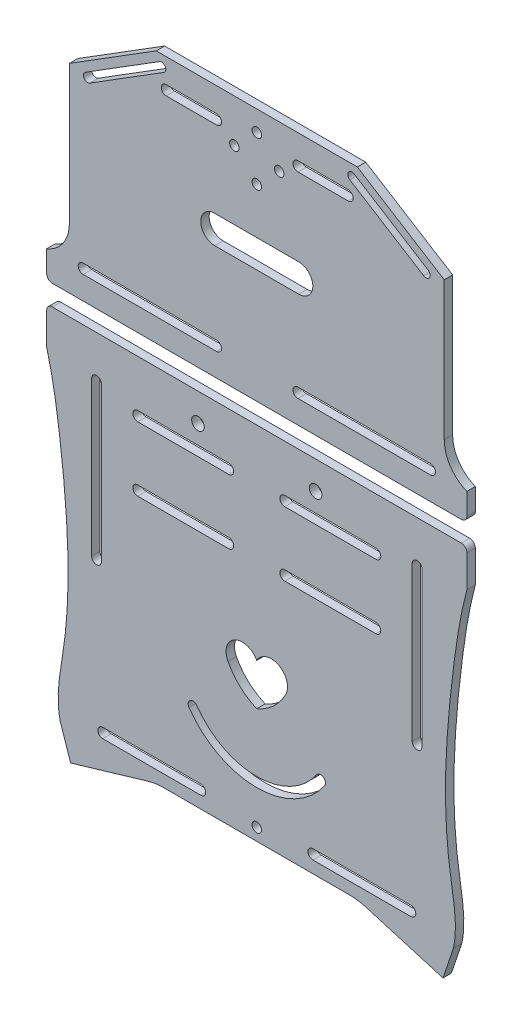
from build123d import *

# Parameters (mm, degrees)
EXTRUDE_1_DEPTH      = 3
SKETCH_7_R           = 1.75
SKETCH_7_R_2         = 2.25
CUT_EXTRUDE_2_DEPTH  = 143.955430949
CUT_EXTRUDE_4_DEPTH  = 3
CUT_EXTRUDE_5_DEPTH  = 3
CUT_EXTRUDE_8_DEPTH  = 3
SKETCH_12_R          = 1.7
CUT_EXTRUDE_9_DEPTH  = 3
SKETCH_13_R          = 1.7
CUT_EXTRUDE_11_DEPTH = 3
CUT_EXTRUDE_12_DEPTH = 143.955430949
FILLET_1_R           = 2
FILLET_2_R           = 2
CUT_EXTRUDE_13_DEPTH = 143.955430949
CUT_EXTRUDE_15_DEPTH = 143.955430949
CUT_EXTRUDE_16_DEPTH = 143.955430949
SKETCH_20_W          = 133.80338819
SKETCH_20_H          = 42.989432067
EXTRUDE_2_DEPTH      = 3
SKETCH_21_W          = 129.207272524
SKETCH_21_H          = 38.788932745
EXTRUDE_3_DEPTH      = 3
SKETCH_22_W          = 20.868569364
SKETCH_22_H          = 31.210515244
SKETCH_22_W_2        = 21.053246969
SKETCH_22_H_2        = 30.102449614
EXTRUDE_4_DEPTH      = 3
SKETCH_24_W          = 36.300662223
SKETCH_24_H          = 5.953308604
SKETCH_24_W_2        = 36.591067521
EXTRUDE_5_DEPTH      = 3
CUT_EXTRUDE_17_DEPTH = 143.955430949
CUT_EXTRUDE_19_DEPTH = 143.955430949
CUT_EXTRUDE_20_DEPTH = 143.955430949
CUT_EXTRUDE_21_DEPTH = 143.955430949
CUT_EXTRUDE_22_DEPTH = 143.955430949
CUT_EXTRUDE_23_DEPTH = 3


with BuildPart() as part:
    # 草图1 → 凸台-拉伸1 (new body)
    with BuildSketch(Plane.XY):
        with BuildLine():
            Line((60, 106.603296002), (35.889163634, 121.664519159))
            Line((35.889163634, 121.664519159), (-35.889163634, 121.664519159))
            Line((-35.889163634, 121.664519159), (-60, 106.603296002))
            Line((-60, 106.603296002), (-60, 94.801892265))
            Line((-60, 94.801892265), (-45, 94.801892265))
            ThreePointArc((-45, 94.801892265), (-43.762563133, 94.289329132), (-43.25, 93.051892265))
            Line((-43.25, 93.051892265), (-37.75, 93.051892265))
            ThreePointArc((-37.75, 93.051892265), (-37.237436867, 94.289329132), (-36, 94.801892265))
            Line((-36, 94.801892265), (-21, 94.801892265))
            ThreePointArc((-21, 94.801892265), (-19.762563133, 94.289329132), (-19.25, 93.051892265))
            Line((-19.25, 93.051892265), (19.25, 93.051892265))
            ThreePointArc((19.25, 93.051892265), (19.762563133, 94.289329132), (21, 94.801892265))
            Line((21, 94.801892265), (36, 94.801892265))
            ThreePointArc((36, 94.801892265), (37.237436867, 94.289329132), (37.75, 93.051892265))
            Line((37.75, 93.051892265), (43.25, 93.051892265))
            ThreePointArc((43.25, 93.051892265), (43.762563133, 94.289329132), (45, 94.801892265))
            Line((45, 94.801892265), (60, 94.801892265))
            Line((60, 94.801892265), (60, 106.603296002))
        make_face()
        with BuildLine():
            Line((66.901694095, 102.292041372), (60, 106.603296002))
            Line((60, 106.603296002), (60, 94.801892265))
            ThreePointArc((60, 94.801892265), (61.237436867, 94.289329132), (61.75, 93.051892265))
            Line((61.75, 93.051892265), (66.901694095, 93.051892265))
            Line((66.901694095, 93.051892265), (66.901694095, 102.292041372))
        make_face()
        with BuildLine():
            Line((-60, 94.801892265), (-60, 106.603296002))
            Line((-60, 106.603296002), (-66.901694095, 102.292041372))
            Line((-66.901694095, 102.292041372), (-66.901694095, 93.051892265))
            Line((-66.901694095, 93.051892265), (-61.75, 93.051892265))
            ThreePointArc((-61.75, 93.051892265), (-61.237436867, 94.289329132), (-60, 94.801892265))
        make_face()
        with BuildLine():
            Line((66.901694095, 63.051892265), (66.901694095, 93.051892265))
            Line((66.901694095, 93.051892265), (61.75, 93.051892265))
            ThreePointArc((61.75, 93.051892265), (61.237436867, 91.814455398), (60, 91.301892265))
            Line((60, 91.301892265), (60, 64.801892265))
            ThreePointArc((60, 64.801892265), (61.237436867, 64.289329132), (61.75, 63.051892265))
            Line((61.75, 63.051892265), (66.901694095, 63.051892265))
        make_face()
        with BuildLine():
            Line((-61.75, 93.051892265), (-66.901694095, 93.051892265))
            Line((-66.901694095, 93.051892265), (-66.901694095, 63.051892265))
            Line((-66.901694095, 63.051892265), (-61.75, 63.051892265))
            ThreePointArc((-61.75, 63.051892265), (-61.237436867, 64.289329132), (-60, 64.801892265))
            Line((-60, 64.801892265), (-60, 91.301892265))
            ThreePointArc((-60, 91.301892265), (-61.237436867, 91.814455398), (-61.75, 93.051892265))
        make_face()
        with BuildLine():
            Line((66.901694095, 52.870133869), (66.901694095, 63.051892265))
            Line((66.901694095, 63.051892265), (61.75, 63.051892265))
            ThreePointArc((61.75, 63.051892265), (61.237436867, 61.814455398), (60, 61.301892265))
            Line((60, 61.301892265), (60, 31.261343001))
            Line((60, 31.261343001), (75, 31.261343001))
            Line((75, 31.261343001), (75, 40.933889795))
            ThreePointArc((75, 40.933889795), (69.117351927, 45.658052319), (66.901694095, 52.870133869))
        make_face()
        with BuildLine():
            Line((60, 64.801892265), (60, 91.301892265))
            Line((60, 91.301892265), (45, 91.301892265))
            ThreePointArc((45, 91.301892265), (43.762563133, 91.814455398), (43.25, 93.051892265))
            Line((43.25, 93.051892265), (37.75, 93.051892265))
            ThreePointArc((37.75, 93.051892265), (37.237436867, 91.814455398), (36, 91.301892265))
            Line((36, 91.301892265), (21, 91.301892265))
            ThreePointArc((21, 91.301892265), (19.762563133, 91.814455398), (19.25, 93.051892265))
            Line((19.25, 93.051892265), (-19.25, 93.051892265))
            ThreePointArc((-19.25, 93.051892265), (-19.762563133, 91.814455398), (-21, 91.301892265))
            Line((-21, 91.301892265), (-36, 91.301892265))
            ThreePointArc((-36, 91.301892265), (-37.237436867, 91.814455398), (-37.75, 93.051892265))
            Line((-37.75, 93.051892265), (-43.25, 93.051892265))
            ThreePointArc((-43.25, 93.051892265), (-43.762563133, 91.814455398), (-45, 91.301892265))
            Line((-45, 91.301892265), (-60, 91.301892265))
            Line((-60, 91.301892265), (-60, 64.801892265))
            Line((-60, 64.801892265), (-45, 64.801892265))
            ThreePointArc((-45, 64.801892265), (-43.762563133, 64.289329132), (-43.25, 63.051892265))
            Line((-43.25, 63.051892265), (-37.75, 63.051892265))
            ThreePointArc((-37.75, 63.051892265), (-37.237436867, 64.289329132), (-36, 64.801892265))
            Line((-36, 64.801892265), (-21, 64.801892265))
            ThreePointArc((-21, 64.801892265), (-19.762563133, 64.289329132), (-19.25, 63.051892265))
            Line((-19.25, 63.051892265), (19.25, 63.051892265))
            ThreePointArc((19.25, 63.051892265), (19.762563133, 64.289329132), (21, 64.801892265))
            Line((21, 64.801892265), (36, 64.801892265))
            ThreePointArc((36, 64.801892265), (37.237436867, 64.289329132), (37.75, 63.051892265))
            Line((37.75, 63.051892265), (43.25, 63.051892265))
            ThreePointArc((43.25, 63.051892265), (43.762563133, 64.289329132), (45, 64.801892265))
            Line((45, 64.801892265), (60, 64.801892265))
        make_face()
        with BuildLine():
            Line((-61.75, 63.051892265), (-66.901694095, 63.051892265))
            Line((-66.901694095, 63.051892265), (-66.901694095, 52.870133869))
            ThreePointArc((-66.901694095, 52.870133869), (-69.117351927, 45.658052319), (-75, 40.933889795))
            Line((-75, 40.933889795), (-75, 31.261343001))
            Line((-75, 31.261343001), (-60, 31.261343001))
            Line((-60, 31.261343001), (-60, 61.301892265))
            ThreePointArc((-60, 61.301892265), (-61.237436867, 61.814455398), (-61.75, 63.051892265))
        make_face()
        with BuildLine():
            Line((60, 31.261343001), (60, 61.301892265))
            Line((60, 61.301892265), (45, 61.301892265))
            ThreePointArc((45, 61.301892265), (43.762563133, 61.814455398), (43.25, 63.051892265))
            Line((43.25, 63.051892265), (37.75, 63.051892265))
            ThreePointArc((37.75, 63.051892265), (37.237436867, 61.814455398), (36, 61.301892265))
            Line((36, 61.301892265), (21, 61.301892265))
            ThreePointArc((21, 61.301892265), (19.762563133, 61.814455398), (19.25, 63.051892265))
            Line((19.25, 63.051892265), (-19.25, 63.051892265))
            ThreePointArc((-19.25, 63.051892265), (-19.762563133, 61.814455398), (-21, 61.301892265))
            Line((-21, 61.301892265), (-36, 61.301892265))
            ThreePointArc((-36, 61.301892265), (-37.237436867, 61.814455398), (-37.75, 63.051892265))
            Line((-37.75, 63.051892265), (-43.25, 63.051892265))
            ThreePointArc((-43.25, 63.051892265), (-43.762563133, 61.814455398), (-45, 61.301892265))
            Line((-45, 61.301892265), (-60, 61.301892265))
            Line((-60, 61.301892265), (-60, 31.261343001))
            Line((-60, 31.261343001), (60, 31.261343001))
        make_face()
        with BuildLine():
            Line((60, -58.312864289), (60, 23.940028391))
            Line((60, 23.940028391), (-60, 23.940028391))
            Line((-60, 23.940028391), (-60, -58.312864289))
            Line((-60, -58.312864289), (-45, -58.312864289))
            ThreePointArc((-45, -58.312864289), (-43.25, -60.062864289), (-45, -61.812864289))
            Line((-45, -61.812864289), (-60, -61.812864289))
            Line((-60, -61.812864289), (-60, -88.312864289))
            Line((-60, -88.312864289), (-45, -88.312864289))
            ThreePointArc((-45, -88.312864289), (-43.25, -90.062864289), (-45, -91.812864289))
            Line((-45, -91.812864289), (-60, -91.812864289))
            Line((-60, -91.812864289), (-60, -111.849967256))
            Line((-60, -111.849967256), (-38.845469114, -105.590576733))
            ThreePointArc((-38.845469114, -105.590576733), (-36.037784492, -104.975210108), (-33.17088573, -104.768665882))
            Line((-33.17088573, -104.768665882), (33.17088573, -104.768665882))
            ThreePointArc((33.17088573, -104.768665882), (36.037784492, -104.975210108), (38.845469114, -105.590576733))
            Line((38.845469114, -105.590576733), (60, -111.849967256))
            Line((60, -111.849967256), (60, -91.812864289))
            Line((60, -91.812864289), (45, -91.812864289))
            ThreePointArc((45, -91.812864289), (43.762563133, -91.300301156), (43.25, -90.062864289))
            ThreePointArc((43.25, -90.062864289), (43.762563133, -88.825427422), (45, -88.312864289))
            Line((45, -88.312864289), (60, -88.312864289))
            Line((60, -88.312864289), (60, -61.812864289))
            Line((60, -61.812864289), (45, -61.812864289))
            ThreePointArc((45, -61.812864289), (43.762563133, -61.300301156), (43.25, -60.062864289))
            ThreePointArc((43.25, -60.062864289), (43.762563133, -58.825427422), (45, -58.312864289))
            Line((45, -58.312864289), (60, -58.312864289))
        make_face()
        with BuildLine():
            ThreePointArc((-21, -88.312864289), (-19.762563133, -88.825427422), (-19.25, -90.062864289))
            ThreePointArc((-19.25, -90.062864289), (-19.762563133, -91.300301156), (-21, -91.812864289))
            Line((-21, -91.812864289), (-36, -91.812864289))
            ThreePointArc((-36, -91.812864289), (-37.75, -90.062864289), (-36, -88.312864289))
            Line((-36, -88.312864289), (-21, -88.312864289))
        make_face(mode=Mode.SUBTRACT)
        with BuildLine():
            ThreePointArc((-21, -58.312864289), (-19.762563133, -58.825427422), (-19.25, -60.062864289))
            ThreePointArc((-19.25, -60.062864289), (-19.762563133, -61.300301156), (-21, -61.812864289))
            Line((-21, -61.812864289), (-36, -61.812864289))
            ThreePointArc((-36, -61.812864289), (-37.75, -60.062864289), (-36, -58.312864289))
            Line((-36, -58.312864289), (-21, -58.312864289))
        make_face(mode=Mode.SUBTRACT)
        with BuildLine():
            ThreePointArc((36, -88.312864289), (37.237436867, -88.825427422), (37.75, -90.062864289))
            ThreePointArc((37.75, -90.062864289), (37.237436867, -91.300301156), (36, -91.812864289))
            Line((36, -91.812864289), (21, -91.812864289))
            ThreePointArc((21, -91.812864289), (19.762563133, -91.300301156), (19.25, -90.062864289))
            ThreePointArc((19.25, -90.062864289), (19.762563133, -88.825427422), (21, -88.312864289))
            Line((21, -88.312864289), (36, -88.312864289))
        make_face(mode=Mode.SUBTRACT)
        with BuildLine():
            ThreePointArc((36, -58.312864289), (37.237436867, -58.825427422), (37.75, -60.062864289))
            ThreePointArc((37.75, -60.062864289), (37.237436867, -61.300301156), (36, -61.812864289))
            Line((36, -61.812864289), (21, -61.812864289))
            ThreePointArc((21, -61.812864289), (19.762563133, -61.300301156), (19.25, -60.062864289))
            ThreePointArc((19.25, -60.062864289), (19.762563133, -58.825427422), (21, -58.312864289))
            Line((21, -58.312864289), (36, -58.312864289))
        make_face(mode=Mode.SUBTRACT)
        with BuildLine():
            Line((75, 23.940028391), (60, 23.940028391))
            Line((60, 23.940028391), (60, -58.312864289))
            ThreePointArc((60, -58.312864289), (61.237436867, -58.825427422), (61.75, -60.062864289))
            Line((61.75, -60.062864289), (67.402721334, -60.062864289))
            add(Edge.make_bspline(
                [(75, 10.562559835), (72.695878257, 1.907314233), (70.339582535, -13.372796253), (67.818206704, -36.939032951), (67.208860388, -51.77269444), (67.402721334, -60.062864289)],
                knots=[0, 0, 0, 0, 0.235246678, 0.40629419, 0.624108181, 0.624108181, 0.624108181, 0.624108181], degree=3))
            Line((75, 10.562559835), (75, 23.940028391))
        make_face()
        with BuildLine():
            Line((-60, -58.312864289), (-60, 23.940028391))
            Line((-60, 23.940028391), (-75, 23.940028391))
            Line((-75, 23.940028391), (-75, 10.562559835))
            add(Edge.make_bspline(
                [(-75, 10.562559835), (-72.695878257, 1.907314233), (-70.339582535, -13.372796253), (-67.818206704, -36.939032951), (-67.208860388, -51.77269444), (-67.402721334, -60.062864289)],
                knots=[0, 0, 0, 0, 0.235246678, 0.40629419, 0.624108181, 0.624108181, 0.624108181, 0.624108181], degree=3))
            add(Edge.make_bspline(
                [(-67.402721334, -60.062864289), (-67.560325872, -66.802583754), (-68.323504015, -76.843670093), (-70.154131955, -86.778530076), (-70.533712858, -90.062864289)],
                knots=[0.624108181, 0.624108181, 0.624108181, 0.624108181, 0.801186001, 0.888408652, 0.888408652, 0.888408652, 0.888408652], degree=3))
            add(Edge.make_bspline(
                [(-70.533712858, -90.062864289), (-71.019342956, -94.264792095), (-71.137422935, -98.476048206), (-70.1742624, -102.732794059)],
                knots=[0.888408652, 0.888408652, 0.888408652, 0.888408652, 1, 1, 1, 1], degree=3))
            Line((-70.1742624, -102.732794059), (-66.460817635, -113.761651372))
            Line((-66.460817635, -113.761651372), (-60, -111.849967256))
            Line((-60, -111.849967256), (-60, -91.812864289))
            ThreePointArc((-60, -91.812864289), (-61.75, -90.062864289), (-60, -88.312864289))
            Line((-60, -88.312864289), (-60, -61.812864289))
            ThreePointArc((-60, -61.812864289), (-61.75, -60.062864289), (-60, -58.312864289))
        make_face()
        with BuildLine():
            Line((67.402721334, -60.062864289), (61.75, -60.062864289))
            ThreePointArc((61.75, -60.062864289), (61.237436867, -61.300301156), (60, -61.812864289))
            Line((60, -61.812864289), (60, -88.312864289))
            ThreePointArc((60, -88.312864289), (61.237436867, -88.825427422), (61.75, -90.062864289))
            Line((61.75, -90.062864289), (70.533712858, -90.062864289))
            add(Edge.make_bspline(
                [(67.402721334, -60.062864289), (67.560325872, -66.802583754), (68.323504015, -76.843670093), (70.154131955, -86.778530076), (70.533712858, -90.062864289)],
                knots=[0.624108181, 0.624108181, 0.624108181, 0.624108181, 0.801186001, 0.888408652, 0.888408652, 0.888408652, 0.888408652], degree=3))
        make_face()
        with BuildLine():
            add(Edge.make_bspline(
                [(70.533712858, -90.062864289), (71.019342956, -94.264792095), (71.137422935, -98.476048206), (70.1742624, -102.732794059)],
                knots=[0.888408652, 0.888408652, 0.888408652, 0.888408652, 1, 1, 1, 1], degree=3))
            Line((70.533712858, -90.062864289), (61.75, -90.062864289))
            ThreePointArc((61.75, -90.062864289), (61.237436867, -91.300301156), (60, -91.812864289))
            Line((60, -91.812864289), (60, -111.849967256))
            Line((60, -111.849967256), (66.460817635, -113.761651372))
            Line((66.460817635, -113.761651372), (70.1742624, -102.732794059))
        make_face()
    extrude(amount=EXTRUDE_1_DEPTH)

    # 草图7 → 切除-拉伸2 (cut, through all)
    with BuildSketch(Plane(origin=(0, 0, 0), x_dir=(-1, 0, 0), z_dir=(0, 0, -1))):
        with Locations((-21, 41.261343001)):
            Circle(SKETCH_7_R)
        with Locations((21, 41.261343001)):
            Circle(SKETCH_7_R)
        with Locations((-21, 13.940028391)):
            Circle(SKETCH_7_R_2)
        with Locations((21, 13.940028391)):
            Circle(SKETCH_7_R_2)
    extrude(amount=-CUT_EXTRUDE_2_DEPTH, mode=Mode.SUBTRACT)

    # 草图9 → 切除-拉伸4 (cut)
    with BuildSketch(Plane.XY.offset(3)):
        with BuildLine():
            Line((55, -100.49704609), (20, -100.49704609))
            ThreePointArc((20, -100.49704609), (18.25, -98.74704609), (20, -96.99704609))
            Line((20, -96.99704609), (55, -96.99704609))
            ThreePointArc((55, -96.99704609), (56.75, -98.74704609), (55, -100.49704609))
        make_face()
        with BuildLine():
            Line((-55, -96.99704609), (-20, -96.99704609))
            ThreePointArc((-20, -96.99704609), (-18.25, -98.74704609), (-20, -100.49704609))
            Line((-20, -100.49704609), (-55, -100.49704609))
            ThreePointArc((-55, -100.49704609), (-56.75, -98.74704609), (-55, -96.99704609))
        make_face()
    extrude(amount=-CUT_EXTRUDE_4_DEPTH, mode=Mode.SUBTRACT)

    # 草图10 → 切除-拉伸5 (cut)
    with BuildSketch(Plane.XY.offset(3)):
        with BuildLine():
            Line((12.5, -80.062864289), (-12.5, -80.062864289))
            ThreePointArc((-12.5, -80.062864289), (-17.5, -75.062864289), (-12.5, -70.062864289))
            Line((-12.5, -70.062864289), (12.5, -70.062864289))
            ThreePointArc((12.5, -70.062864289), (17.5, -75.062864289), (12.5, -80.062864289))
        make_face()
    extrude(amount=-CUT_EXTRUDE_5_DEPTH, mode=Mode.SUBTRACT)

    # 草图11 → 切除-拉伸8 (cut)
    with BuildSketch(Plane.XY.offset(3)):
        with BuildLine():
            Line((15, 73.051892265), (-15, 73.051892265))
            ThreePointArc((-15, 73.051892265), (-20, 78.051892265), (-15, 83.051892265))
            Line((-15, 83.051892265), (15, 83.051892265))
            ThreePointArc((15, 83.051892265), (20, 78.051892265), (15, 73.051892265))
        make_face()
    extrude(amount=-CUT_EXTRUDE_8_DEPTH, mode=Mode.SUBTRACT)

    # 草图12 → 切除-拉伸9 (cut)
    with BuildSketch(Plane.XY.offset(3)):
        with Locations((0, 114.371786435)):
            Circle(SKETCH_12_R)
        with Locations((0, 98.371786435)):
            Circle(SKETCH_12_R)
        with Locations((8, 106.371786435)):
            Circle(SKETCH_12_R)
        with Locations((-8, 106.371786435)):
            Circle(SKETCH_12_R)
    extrude(amount=-CUT_EXTRUDE_9_DEPTH, mode=Mode.SUBTRACT)

    # 草图13 → 切除-拉伸11 (cut)
    with BuildSketch(Plane.XY.offset(3)):
        with Locations((0, -84.415765086)):
            Circle(SKETCH_13_R)
        with Locations((8, -92.415765086)):
            Circle(SKETCH_13_R)
        with Locations((0, -100.415765086)):
            Circle(SKETCH_13_R)
        with Locations((-8, -92.415765086)):
            Circle(SKETCH_13_R)
    extrude(amount=-CUT_EXTRUDE_11_DEPTH, mode=Mode.SUBTRACT)

    # 草图14 → 切除-拉伸12 (cut, through all)
    with BuildSketch(Plane.XY.offset(3)):
        with BuildLine():
            Line((-55.475501567, 8.919687236), (-55.475501567, -46.080312764))
            ThreePointArc((-55.475501567, -46.080312764), (-57.225501567, -47.830312764), (-58.975501567, -46.080312764))
            Line((-58.975501567, -46.080312764), (-58.975501567, 8.919687236))
            ThreePointArc((-58.975501567, 8.919687236), (-57.225501567, 10.669687236), (-55.475501567, 8.919687236))
        make_face()
        with BuildLine():
            Line((58.975501567, 8.919687236), (58.975501567, -46.080312764))
            ThreePointArc((58.975501567, -46.080312764), (57.225501567, -47.830312764), (55.475501567, -46.080312764))
            Line((55.475501567, -46.080312764), (55.475501567, 8.919687236))
            ThreePointArc((55.475501567, 8.919687236), (57.225501567, 10.669687236), (58.975501567, 8.919687236))
        make_face()
    extrude(amount=-CUT_EXTRUDE_12_DEPTH, mode=Mode.SUBTRACT)

    # 圆角1
    fillet_1_edges = [part.edges().sort_by_distance(p)[0] for p in [
        (75, 31.261343001, 1.5),
        (-75, 31.261343001, 1.5),
    ]]
    fillet(fillet_1_edges, radius=FILLET_1_R)

    # 圆角2
    fillet_2_edges = [part.edges().sort_by_distance(p)[0] for p in [
        (-75, 23.940028391, 1.5),
        (75, 23.940028391, 1.5),
    ]]
    fillet(fillet_2_edges, radius=FILLET_2_R)

    # 草图15 → 切除-拉伸13 (cut, through all)
    with BuildSketch(Plane(origin=(0, 0, 0), x_dir=(-1, 0, 0), z_dir=(0, 0, -1))):
        with BuildLine():
            Line((-61.184216401, 102.403501276), (-34.774762862, 118.900592756))
            ThreePointArc((-34.774762862, 118.900592756), (-32.70788159, 118.423097411), (-33.185376934, 116.356216138))
            Line((-33.185376934, 116.356216138), (-59.594830473, 99.859124658))
            ThreePointArc((-59.594830473, 99.859124658), (-61.661711746, 100.336620003), (-61.184216401, 102.403501276))
        make_face()
        with BuildLine():
            Line((59.594830473, 99.859124658), (33.185376934, 116.356216138))
            ThreePointArc((33.185376934, 116.356216138), (32.70788159, 118.423097411), (34.774762862, 118.900592756))
            Line((34.774762862, 118.900592756), (61.184216401, 102.403501276))
            ThreePointArc((61.184216401, 102.403501276), (61.661711746, 100.336620003), (59.594830473, 99.859124658))
        make_face()
    extrude(amount=-CUT_EXTRUDE_13_DEPTH, mode=Mode.SUBTRACT)

    # 草图17 → 切除-拉伸15 (cut, through all)
    with BuildSketch(Plane(origin=(0, 0, 0), x_dir=(-1, 0, 0), z_dir=(0, 0, -1))):
        Polygon((-28.645414283, -8.118433382), (-34.644957411, -20.11751964), (-34.644957411, -29.946558382), (-37.580904049, -29.946558382), (-37.580904049, -20.11751964), (-43.580447177, -8.118433382), (-40.64450054, -8.118433382), (-36.176755657, -17.43687271), (-36.049105803, -17.43687271), (-31.58136092, -8.118433382), align=None)
    extrude(amount=-CUT_EXTRUDE_15_DEPTH, mode=Mode.SUBTRACT)

    # 草图18 → 切除-拉伸16 (cut, through all)
    with BuildSketch(Plane(origin=(0, 0, 0), x_dir=(-1, 0, 0), z_dir=(0, 0, -1))):
        Polygon((46.06697123, -29.087529791), (43.131024593, -29.087529791), (43.131024593, -18.875541487), (35.854982926, -18.875541487), (35.854982926, -29.087529791), (32.919036289, -29.087529791), (32.919036289, -7.259404791), (35.854982926, -7.259404791), (35.854982926, -16.450194265), (43.131024593, -16.450194265), (43.131024593, -7.259404791), (46.06697123, -7.259404791), align=None)
    extrude(amount=-CUT_EXTRUDE_16_DEPTH, mode=Mode.SUBTRACT)

    # 草图20 → 凸台-拉伸2 (add)
    with BuildSketch(Plane(origin=(0, 0, 0), x_dir=(-1, 0, 0), z_dir=(0, 0, -1))):
        with Locations((0, 74.364849902)):
            Rectangle(SKETCH_20_W, SKETCH_20_H)
    extrude(amount=-EXTRUDE_2_DEPTH)

    # 草图21 → 凸台-拉伸3 (add)
    with BuildSketch(Plane(origin=(0, 0, 0), x_dir=(-1, 0, 0), z_dir=(0, 0, -1))):
        with Locations((-0.162688936, -75.817262983)):
            Rectangle(SKETCH_21_W, SKETCH_21_H)
    extrude(amount=-EXTRUDE_3_DEPTH)

    # 草图22 → 凸台-拉伸4 (add)
    with BuildSketch(Plane(origin=(0, 0, 0), x_dir=(-1, 0, 0), z_dir=(0, 0, -1))):
        with Locations((-36.28455521, -18.718035035)):
            Rectangle(SKETCH_22_W, SKETCH_22_H)
        with Locations((39.340924035, -18.16400222)):
            Rectangle(SKETCH_22_W_2, SKETCH_22_H_2)
    extrude(amount=-EXTRUDE_4_DEPTH)

    # 草图24 → 凸台-拉伸5 (add)
    with BuildSketch(Plane(origin=(0, 0, 0), x_dir=(-1, 0, 0), z_dir=(0, 0, -1))):
        with Locations((-46.84572901, 41.350914957)):
            Rectangle(SKETCH_24_W, SKETCH_24_H)
        with Locations((47.53599277, 41.350914957)):
            Rectangle(SKETCH_24_W_2, SKETCH_24_H)
    extrude(amount=-EXTRUDE_5_DEPTH)

    # 草图25 → 切除-拉伸17 (cut, through all)
    with BuildSketch(Plane(origin=(0, 0, 0), x_dir=(-1, 0, 0), z_dir=(0, 0, -1))):
        with BuildLine():
            Line((-14.658238954, 113.011343001), (-32.658238954, 113.011343001))
            ThreePointArc((-32.658238954, 113.011343001), (-34.408238954, 111.261343001), (-32.658238954, 109.511343001))
            Line((-32.658238954, 109.511343001), (-14.658238954, 109.511343001))
            ThreePointArc((-14.658238954, 109.511343001), (-12.908238954, 111.261343001), (-14.658238954, 113.011343001))
        make_face()
        with BuildLine():
            Line((-20.999999982, 43.011343001), (-32.658238954, 43.011343001))
            ThreePointArc((-32.658238954, 43.011343001), (-34.408238954, 41.261343001), (-32.658238954, 39.511343001))
            Line((-32.658238954, 39.511343001), (-21, 39.511343001))
            ThreePointArc((-21, 39.511343001), (-22.75, 41.26134301), (-20.999999982, 43.011343001))
        make_face()
        with BuildLine():
            ThreePointArc((14.341761046, 113.011343001), (12.591761046, 111.261343001), (14.341761046, 109.511343001))
            Line((14.341761046, 109.511343001), (32.341761046, 109.511343001))
            ThreePointArc((32.341761046, 109.511343001), (34.091761046, 111.261343001), (32.341761046, 113.011343001))
            Line((32.341761046, 113.011343001), (14.341761046, 113.011343001))
        make_face()
        with BuildLine():
            Line((-14.658238954, 43.011343001), (-20.999999982, 43.011343001))
            ThreePointArc((-20.999999982, 43.011343001), (-19.25, 41.261342991), (-21, 39.511343001))
            Line((-21, 39.511343001), (-14.658238954, 39.511343001))
            ThreePointArc((-14.658238954, 39.511343001), (-12.908238954, 41.261343001), (-14.658238954, 43.011343001))
        make_face()
        with BuildLine():
            ThreePointArc((32.341761046, 39.511343001), (34.091761046, 41.261343001), (32.341761046, 43.011343001))
            Line((32.341761046, 43.011343001), (21, 43.011343001))
            ThreePointArc((21, 43.011343001), (22.75, 41.261343001), (21, 39.511343001))
            Line((21, 39.511343001), (32.341761046, 39.511343001))
        make_face()
        with BuildLine():
            ThreePointArc((14.341761046, 43.011343001), (12.591761046, 41.261343001), (14.341761046, 39.511343001))
            Line((14.341761046, 39.511343001), (21, 39.511343001))
            ThreePointArc((21, 39.511343001), (19.25, 41.261343001), (21, 43.011343001))
            Line((21, 43.011343001), (14.341761046, 43.011343001))
        make_face()
    extrude(amount=-CUT_EXTRUDE_17_DEPTH, mode=Mode.SUBTRACT)

    # 草图16 → 切除-拉伸19 (cut, through all)
    with BuildSketch(Plane(origin=(0, 0, 0), x_dir=(-1, 0, 0), z_dir=(0, 0, -1))):
        with BuildLine():
            Line((-62, 43.011343001), (-32, 43.011343001))
            ThreePointArc((-32, 43.011343001), (-30.25, 41.261343001), (-32, 39.511343001))
            Line((-32, 39.511343001), (-62, 39.511343001))
            ThreePointArc((-62, 39.511343001), (-63.75, 41.261343001), (-62, 43.011343001))
        make_face()
        with BuildLine():
            Line((62, 39.511343001), (32, 39.511343001))
            ThreePointArc((32, 39.511343001), (30.25, 41.261343001), (32, 43.011343001))
            Line((32, 43.011343001), (62, 43.011343001))
            ThreePointArc((62, 43.011343001), (63.75, 41.261343001), (62, 39.511343001))
        make_face()
    extrude(amount=-CUT_EXTRUDE_19_DEPTH, mode=Mode.SUBTRACT)

    # 草图26 → 切除-拉伸20 (cut, through all)
    with BuildSketch(Plane(origin=(0, 0, 0), x_dir=(-1, 0, 0), z_dir=(0, 0, -1))):
        with BuildLine():
            Line((15, 71.876956146), (-15, 71.876956146))
            ThreePointArc((-15, 71.876956146), (-20, 76.876956146), (-15, 81.876956146))
            Line((-15, 81.876956146), (15, 81.876956146))
            ThreePointArc((15, 81.876956146), (20, 76.876956146), (15, 71.876956146))
        make_face()
    extrude(amount=-CUT_EXTRUDE_20_DEPTH, mode=Mode.SUBTRACT)

    # 草图27 → 切除-拉伸21 (cut, through all)
    with BuildSketch(Plane(origin=(0, 0, 0), x_dir=(-1, 0, 0), z_dir=(0, 0, -1))):
        with BuildLine():
            Line((-10, -15.809971609), (-42.5, -15.809971609))
            ThreePointArc((-42.5, -15.809971609), (-44.25, -17.559971609), (-42.5, -19.309971609))
            Line((-42.5, -19.309971609), (-10, -19.309971609))
            ThreePointArc((-10, -19.309971609), (-8.25, -17.559971609), (-10, -15.809971609))
        make_face()
        with BuildLine():
            ThreePointArc((-42.5, 7.190028391), (-44.25, 5.440028391), (-42.5, 3.690028391))
            Line((-42.5, 3.690028391), (-10, 3.690028391))
            ThreePointArc((-10, 3.690028391), (-8.25, 5.440028391), (-10, 7.190028391))
            Line((-10, 7.190028391), (-42.5, 7.190028391))
        make_face()
        with BuildLine():
            Line((42.5, -15.809971609), (10, -15.809971609))
            ThreePointArc((10, -15.809971609), (8.25, -17.559971609), (10, -19.309971609))
            Line((10, -19.309971609), (42.5, -19.309971609))
            ThreePointArc((42.5, -19.309971609), (44.25, -17.559971609), (42.5, -15.809971609))
        make_face()
        with BuildLine():
            Line((42.5, 7.190028391), (10, 7.190028391))
            ThreePointArc((10, 7.190028391), (8.25, 5.440028391), (10, 3.690028391))
            Line((10, 3.690028391), (42.5, 3.690028391))
            ThreePointArc((42.5, 3.690028391), (44.25, 5.440028391), (42.5, 7.190028391))
        make_face()
    extrude(amount=-CUT_EXTRUDE_21_DEPTH, mode=Mode.SUBTRACT)

    # 草图28 → 切除-拉伸22 (cut, through all)
    with BuildSketch(Plane(origin=(0, 0, 0), x_dir=(-1, 0, 0), z_dir=(0, 0, -1))):
        with BuildLine():
            ThreePointArc((0, -48.812330529), (-7.86916468, -46.39674179), (-10.284753419, -54.26590647))
            ThreePointArc((-10.284753419, -54.26590647), (-5.977554294, -59.915955393), (0, -63.755729058))
            ThreePointArc((0, -63.755729058), (5.977554294, -59.915955393), (10.284753419, -54.26590647))
            ThreePointArc((10.284753419, -54.26590647), (7.86916468, -46.39674179), (0, -48.812330529))
        make_face()
    extrude(amount=-CUT_EXTRUDE_22_DEPTH, mode=Mode.SUBTRACT)

    # 草图29 → 切除-拉伸23 (cut)
    with BuildSketch(Plane(origin=(0, 0, 0), x_dir=(-1, 0, 0), z_dir=(0, 0, -1))):
        with BuildLine():
            ThreePointArc((-21.368709037, -73.490793052), (0, -84.713248851), (21.368709037, -73.490793052))
            ThreePointArc((21.368709037, -73.490793052), (23.760053677, -73.051240341), (24.199606389, -75.442584981))
            ThreePointArc((24.199606389, -75.442584981), (0, -88.151776376), (-24.199606389, -75.442584981))
            ThreePointArc((-24.199606389, -75.442584981), (-23.760053677, -73.051240341), (-21.368709037, -73.490793052))
        make_face()
    extrude(amount=-CUT_EXTRUDE_23_DEPTH, mode=Mode.SUBTRACT)


solid = part.part
